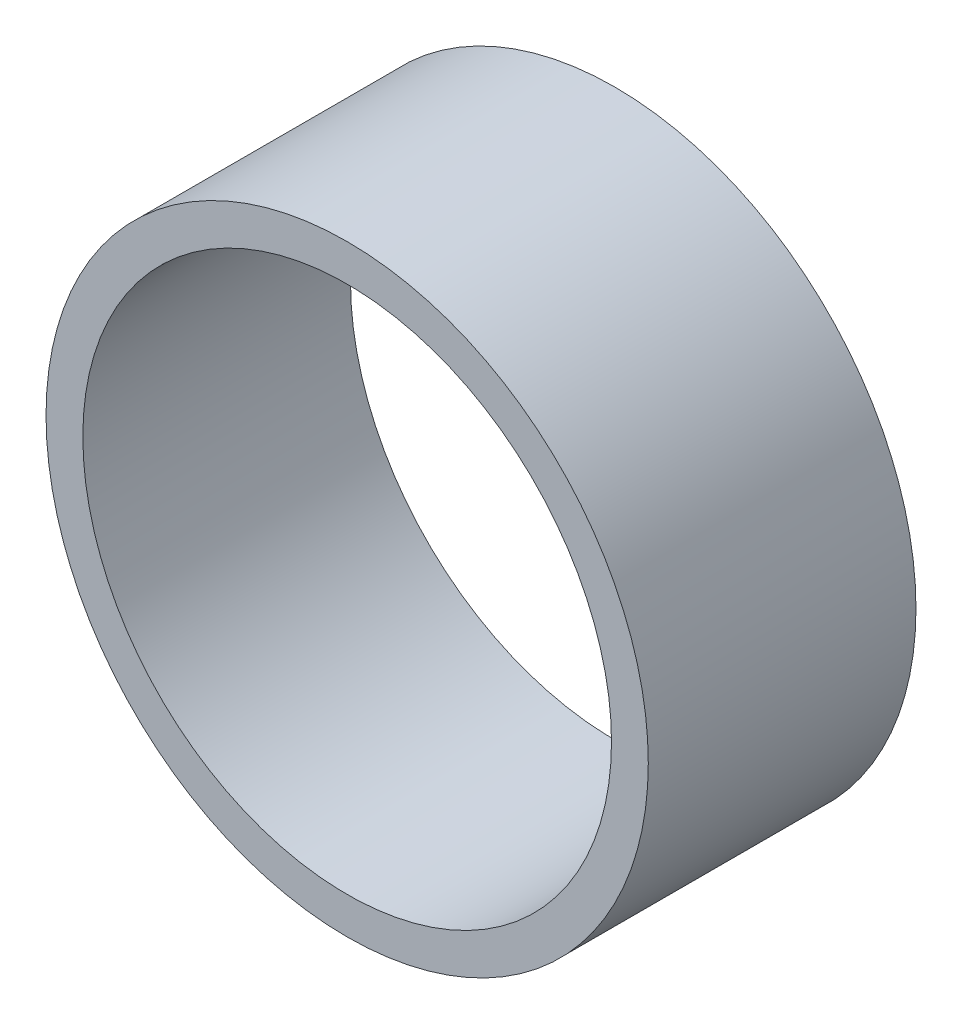
from build123d import *

# Parameters (mm, degrees)
SKETCH1_R           = 28.575
SKETCH1_R_2         = 25.0825
BOSS_EXTRUDE1_DEPTH = 25.4


with BuildPart() as part:
    # Sketch1 → Boss-Extrude1 (new body)
    with BuildSketch(Plane.XY):
        Circle(SKETCH1_R)
        Circle(SKETCH1_R_2, mode=Mode.SUBTRACT)
    extrude(amount=BOSS_EXTRUDE1_DEPTH)


solid = part.part
